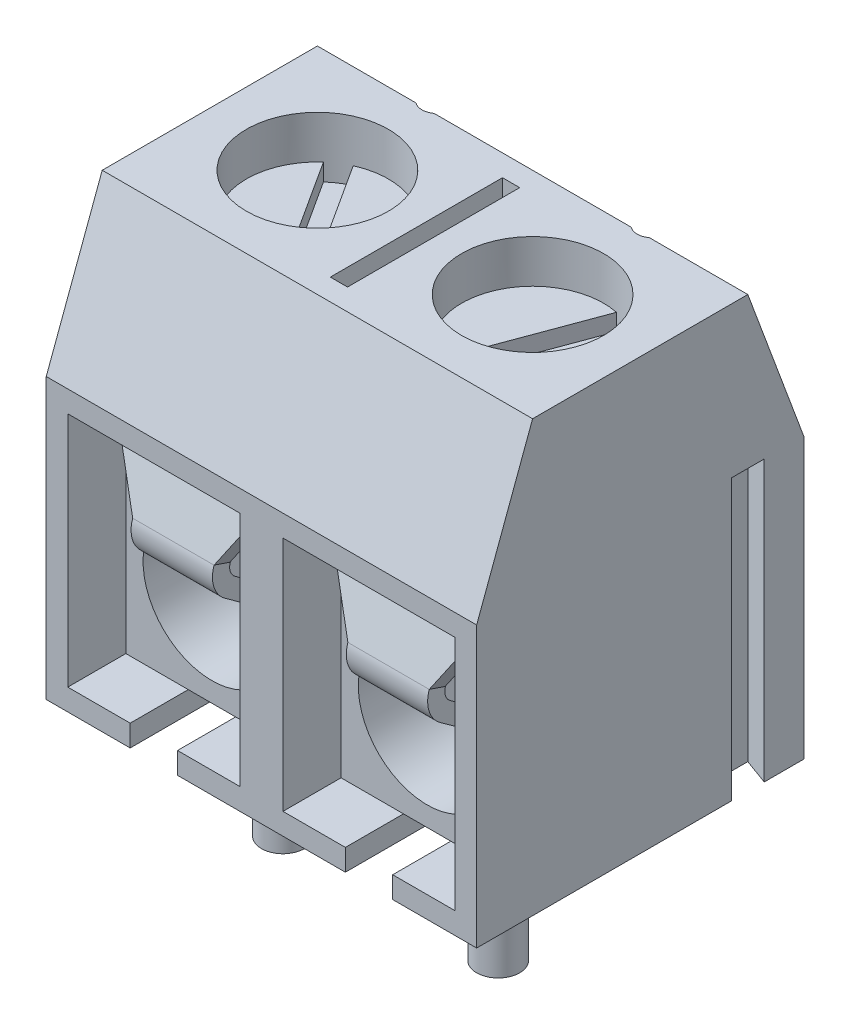
from build123d import *

# Parameters (mm, degrees)
SKETCH1_W               = 10
SKETCH1_H               = 7.6
EXTRUDE1_DEPTH          = 10
SKETCH2_OUTSIDE_W       = 12.81
SKETCH2_OUTSIDE_H       = 15.21
CUT_EXTRUDE1_DEPTH      = 6
CUT_EXTRUDE1_DEPTH_BACK = 6
SKETCH3_R               = 1.65
SKETCH3_R_2             = 0.35
SKETCH3_W               = 0.4
SKETCH3_H               = 4
CUT_EXTRUDE2_DEPTH      = 4
SKETCH4_W               = 4
SKETCH4_H               = 5.5
CUT_EXTRUDE3_DEPTH      = 5.6
SKETCH5_W               = 4
SKETCH5_H               = 5.1
EXTRUDE2_DEPTH          = 4.25
SKETCH6_R               = 1.6
CUT_EXTRUDE4_DEPTH      = 4.25
EXTRUDE3_DEPTH          = 6.5
CUT_EXTRUDE5_DEPTH      = 6.5
SKETCH10_W              = 1.1
SKETCH10_H              = 0.5
CUT_EXTRUDE6_DEPTH      = 3.6
SKETCH11_R              = 0.5
EXTRUDE4_DEPTH          = 3.5
SKETCH12_R              = 1.65
EXTRUDE5_DEPTH          = 3
CUT_EXTRUDE7_DEPTH      = 0.4
EXTRUDE6_DEPTH          = 0.945
EXTRUDE9_DEPTH          = 0.39
LPATTERN1_COUNT         = 2
LPATTERN1_PITCH         = 5
FILLET1_R               = 0.3
FILLET2_R               = 0.7
SCALE1_SCALE            = 0.7


with BuildPart() as part:
    # Sketch1 → Extrude1 (new body)
    with BuildSketch(Plane(origin=(0, 0, 0), x_dir=(1, 0, 0), z_dir=(0, 1, 0))):
        Rectangle(SKETCH1_W, SKETCH1_H)
    extrude(amount=EXTRUDE1_DEPTH)

    # Sketch2 outside → Cut-Extrude1 (cut, two sides)
    with BuildSketch(Plane(origin=(0, 0, 0), x_dir=(0, 0, -1), z_dir=(1, 0, 0))) as cut_extrude1_sk:
        with Locations((0, 5)):
            Rectangle(SKETCH2_OUTSIDE_W, SKETCH2_OUTSIDE_H)
        Polygon((2.5, 10), (3.8, 6.5), (3.8, 0), (-3.8, 0), (-3.8, 6.5), (-2.5, 10), align=None, mode=Mode.SUBTRACT)
    extrude(amount=CUT_EXTRUDE1_DEPTH, mode=Mode.SUBTRACT)
    extrude(cut_extrude1_sk.sketch, amount=-CUT_EXTRUDE1_DEPTH_BACK, mode=Mode.SUBTRACT)

    # Sketch3 → Cut-Extrude2 (cut)
    with BuildSketch(Plane(origin=(0, 10, 0), x_dir=(-1, 0, 0), z_dir=(0, 1, 0))):
        with Locations((2.5, 0)):
            Circle(SKETCH3_R)
        with Locations((-2.5, 0)):
            Circle(SKETCH3_R)
        with Locations((2.5, -2.78)):
            Circle(SKETCH3_R_2)
        with Locations((-2.5, -2.78)):
            Circle(SKETCH3_R_2)
        Rectangle(SKETCH3_W, SKETCH3_H)
    extrude(amount=-CUT_EXTRUDE2_DEPTH, mode=Mode.SUBTRACT)

    # Sketch4 → Cut-Extrude3 (cut)
    with BuildSketch(Plane.XY.offset(3.8)):
        with Locations((-2.5, 3.25)):
            Rectangle(SKETCH4_W, SKETCH4_H)
        with Locations((2.5, 3.25)):
            Rectangle(SKETCH4_W, SKETCH4_H)
    extrude(amount=-CUT_EXTRUDE3_DEPTH, mode=Mode.SUBTRACT)

    # Sketch5 → Extrude2 (add)
    with BuildSketch(Plane.XY.offset(-1.8)):
        with Locations((-2.5, 3.05)):
            Rectangle(SKETCH5_W, SKETCH5_H)
        with Locations((2.5, 3.05)):
            Rectangle(SKETCH5_W, SKETCH5_H)
    extrude(amount=EXTRUDE2_DEPTH)

    # Sketch6 → Cut-Extrude4 (cut)
    with BuildSketch(Plane.XY.offset(2.45)):
        with Locations((-2.5, 2.554263468)):
            Circle(SKETCH6_R)
        with Locations((2.5, 2.554263468)):
            Circle(SKETCH6_R)
    extrude(amount=-CUT_EXTRUDE4_DEPTH, mode=Mode.SUBTRACT)

    # Sketch7 → Extrude3 (add)
    with BuildSketch(Plane(origin=(0, 0, 0), x_dir=(1, 0, 0), z_dir=(0, 1, 0))):
        Polygon((-5.6, 3.1), (-5, 2.881617859), (-5, 2.118382141), (-5.6, 1.9), align=None)
    extrude(amount=EXTRUDE3_DEPTH)

    # Sketch9 → Cut-Extrude5 (cut)
    with BuildSketch(Plane(origin=(0, 0, 0), x_dir=(1, 0, 0), z_dir=(0, 1, 0))):
        Polygon((5, 2.881617859), (4.4, 3.1), (4.4, 1.9), (5, 2.118382141), align=None)
    extrude(amount=CUT_EXTRUDE5_DEPTH, mode=Mode.SUBTRACT)

    # Sketch10 → Cut-Extrude6 (cut)
    with BuildSketch(Plane.XY.offset(3.8)):
        with Locations((-2.5, 0.25)):
            Rectangle(SKETCH10_W, SKETCH10_H)
        with Locations((2.5, 0.25)):
            Rectangle(SKETCH10_W, SKETCH10_H)
    extrude(amount=-CUT_EXTRUDE6_DEPTH, mode=Mode.SUBTRACT)

    # Sketch11 → Extrude4 (add)
    with BuildSketch(Plane.XZ.offset(-0.5)):
        with Locations((-2.5, 0.8)):
            Circle(SKETCH11_R)
        with Locations((2.5, 0.8)):
            Circle(SKETCH11_R)
    extrude(amount=EXTRUDE4_DEPTH)

    # Sketch12 → Extrude5 (add)
    with BuildSketch(Plane.XZ.offset(-6)):
        with Locations((2.5, 0)):
            Circle(SKETCH12_R)
        with Locations((-2.5, 0)):
            Circle(SKETCH12_R)
    extrude(amount=-EXTRUDE5_DEPTH)

    # Sketch13 → Cut-Extrude7 (cut)
    with BuildSketch(Plane(origin=(0, 9, 0), x_dir=(-1, 0, 0), z_dir=(0, 1, 0))):
        with BuildLine():
            Line((3.594307251, -1.234905519), (1.825829895, 1.505986278))
            ThreePointArc((1.825829895, 1.505986278), (1.605433494, 1.386452583), (1.405692749, 1.234905519))
            Line((1.405692749, 1.234905519), (3.174170105, -1.505986278))
            ThreePointArc((3.174170105, -1.505986278), (3.394566506, -1.386452583), (3.594307251, -1.234905519))
        make_face()
        with BuildLine():
            Line((-2.83217089, -1.616218581), (-1.698971441, 1.44251629))
            ThreePointArc((-1.698971441, 1.44251629), (-1.926782442, 1.54723031), (-2.16782911, 1.616218581))
            Line((-2.16782911, 1.616218581), (-3.301028559, -1.44251629))
            ThreePointArc((-3.301028559, -1.44251629), (-3.073217558, -1.54723031), (-2.83217089, -1.616218581))
        make_face()
    extrude(amount=-CUT_EXTRUDE7_DEPTH, mode=Mode.SUBTRACT)

    # Sketch14 → Extrude6 (add, symmetric)
    with BuildSketch(Plane.ZY.offset(2.5)):
        Polygon((2.45, 5.6), (3.03887637, 3.861674443), (0.167170254, 1.787608865), (-0.546359637, 2.097431054), (-0.705673534, 1.730526322), (0.216750724, 1.33), (3.512480259, 3.710312924), (2.736824279, 6), (-1.8, 6), (-1.8, 5.6), align=None)
    extrude6 = extrude(amount=EXTRUDE6_DEPTH, both=True)

    # Sketch15 → Extrude9 (add)
    with BuildSketch(Plane(origin=(0, 1.449355072, 4.278403908), x_dir=(1, 0, 0), z_dir=(0, 0.320850379, 0.947129893))):
        Polygon((-1.555, 4.8), (-1.555, 2.903968921), (-0.51, 4.8), align=None)
        Polygon((-3.445, 4.8), (-3.445, 2.903968921), (-4.49, 4.8), align=None)
    extrude9 = extrude(amount=-EXTRUDE9_DEPTH)

    # LPattern1: Extrude6, Extrude9 ×2
    with Locations(*[(i * LPATTERN1_PITCH, 0, 0) for i in range(1, LPATTERN1_COUNT)]):
        add(extrude6)
        add(extrude9)

    # Fillet1
    fillet1_edges = [part.edges().sort_by_distance(p)[0] for p in [
        (-2.5, 3.861674443, 3.03887637),
        (-2.5, 1.787608865, 0.167170254),
        (2.5, 3.861674443, 3.03887637),
        (2.5, 1.787608865, 0.167170254),
    ]]
    fillet(fillet1_edges, radius=FILLET1_R)

    # Fillet2
    fillet2_edges = [part.edges().sort_by_distance(p)[0] for p in [
        (-2.5, 3.710312924, 3.512480259),
        (-2.5, 1.33, 0.216750724),
        (2.5, 1.33, 0.216750724),
        (2.5, 3.710312924, 3.512480259),
    ]]
    fillet(fillet2_edges, radius=FILLET2_R)


with BuildPart() as part_1:
    # Scale1: scaled about (0, 0, 0)
    add(part.part.scale(SCALE1_SCALE))


solid = part_1.part
